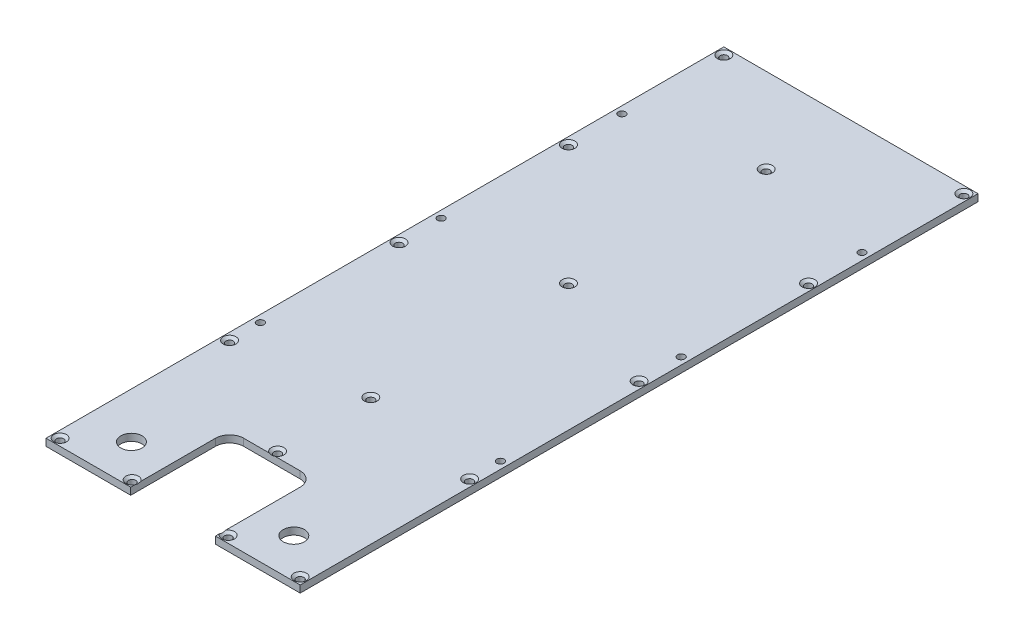
from build123d import *

# Parameters (mm, degrees)
EXTRUDE1_DEPTH                                    = 3.175
CSK_FOR_4_FLAT_HEAD_MACHINE_SCREW_100_D           = 3.2639
CSK_FOR_4_FLAT_HEAD_MACHINE_SCREW_100_CSINK_D     = 5.715
CSK_FOR_4_FLAT_HEAD_MACHINE_SCREW_100_CSINK_ANGLE = 100
FILLET1_R                                         = 6.35
FILLET2_R                                         = 6.35
SKETCH4_R                                         = 4.7625
CUT_EXTRUDE1_DEPTH                                = 4.175
SKETCH5_W                                         = 114.3
SKETCH5_H                                         = 19.05
CUT_EXTRUDE2_DEPTH                                = 4.175
F_4_CLEARANCE_HOLE1_D                             = 3.2639
F_4_CLEARANCE_HOLE1_DEPTH                         = 6.35
F_4_CLEARANCE_HOLE1_TIP                           = 0.980574487


with BuildPart() as part:
    # Sketch1 → Extrude1 (new body)
    with BuildSketch(Plane(origin=(0, 0, 0), x_dir=(1, 0, 0), z_dir=(0, 1, 0))):
        Polygon((-57.15, -171.45), (-57.15, 152.4), (57.15, 152.4), (57.15, -171.45), (19.05, -171.45), (19.05, -107.95), (-19.05, -107.95), (-19.05, -171.45), align=None)
    extrude(amount=EXTRUDE1_DEPTH)

    # CSK for #4 Flat Head Machine Screw (100)1 (through all)
    with Locations(Plane(origin=(-53.975, 3.175, -149.225), x_dir=(0, 0, 1), z_dir=(0, 1, 0))):
        with Locations((0, 0), (0, 107.95), (298.45, 107.95), (298.45, 75.565), (254.635, 53.975), (298.45, 32.385), (298.45, 0), (69.85, 0), (146.05, 0), (222.25, 0), (222.25, 107.95), (146.05, 107.95), (69.85, 107.95), (34.925, 53.975), (212.725, 53.975), (123.825, 53.975)):
            CounterSinkHole(CSK_FOR_4_FLAT_HEAD_MACHINE_SCREW_100_D / 2, CSK_FOR_4_FLAT_HEAD_MACHINE_SCREW_100_CSINK_D / 2, counter_sink_angle=CSK_FOR_4_FLAT_HEAD_MACHINE_SCREW_100_CSINK_ANGLE)

    # Fillet1
    fillet1_edges = [part.edges().sort_by_distance(p)[0] for p in [
        (-19.05, 1.5875, 107.95),
    ]]
    fillet(fillet1_edges, radius=FILLET1_R)

    # Fillet2
    fillet2_edges = [part.edges().sort_by_distance(p)[0] for p in [
        (19.05, 1.5875, 107.95),
    ]]
    fillet(fillet2_edges, radius=FILLET2_R)

    # Sketch4 → Cut-Extrude1 (cut, through all)
    with BuildSketch(Plane(origin=(0, 3.175, 0), x_dir=(-1, 0, 0), z_dir=(0, 1, 0))):
        with Locations((36.5125, 134.62)):
            Circle(SKETCH4_R)
        with Locations((-36.5125, 134.62)):
            Circle(SKETCH4_R)
    extrude(amount=-CUT_EXTRUDE1_DEPTH, mode=Mode.SUBTRACT)

    # Sketch5 → Cut-Extrude2 (cut, through all)
    with BuildSketch(Plane(origin=(0, 3.175, 0), x_dir=(-1, 0, 0), z_dir=(0, 1, 0))):
        with Locations((0, 161.925)):
            Rectangle(SKETCH5_W, SKETCH5_H)
    extrude(amount=-CUT_EXTRUDE2_DEPTH, mode=Mode.SUBTRACT)

    # #4 Clearance Hole1
    with Locations(Plane(origin=(-53.975, 3.175, -103.378), x_dir=(0, 0, 1), z_dir=(0, 1, 0))):
        with Locations((0, 0), (0, 107.95), (81.28, 107.95), (81.28, 0), (162.56, 0), (162.56, 107.95)):
            Hole(F_4_CLEARANCE_HOLE1_D / 2, depth=F_4_CLEARANCE_HOLE1_DEPTH)
            with Locations((0, 0, -(F_4_CLEARANCE_HOLE1_DEPTH + F_4_CLEARANCE_HOLE1_TIP / 2))):  # 118° drill point
                Cone(0, F_4_CLEARANCE_HOLE1_D / 2, F_4_CLEARANCE_HOLE1_TIP, mode=Mode.SUBTRACT)


solid = part.part
